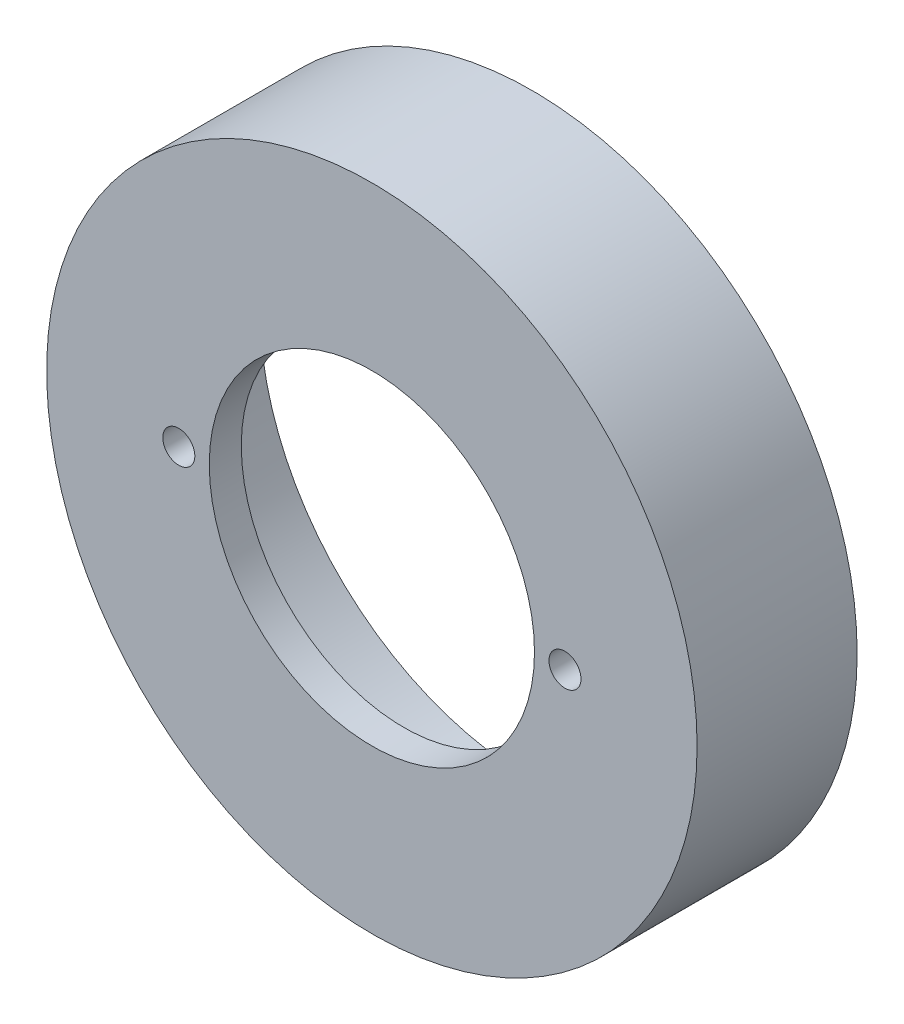
from build123d import *

# Parameters (mm, degrees)
ESQUISSE1_R             = 50.8
BOSS_EXTRU_1_DEPTH      = 25
ESQUISSE2_R             = 25.4
ENL_V_MAT_EXTRU_1_DEPTH = 26
ESQUISSE3_R             = 42.5
ENL_V_MAT_EXTRU_2_DEPTH = 20
ESQUISSE4_R             = 2.5
ENL_V_MAT_EXTRU_3_DEPTH = 6
ESQUISSE5_R             = 2
ENL_V_MAT_EXTRU_4_DEPTH = 7.5


with BuildPart() as part:
    # Esquisse1 → Boss.-Extru.1 (new body)
    with BuildSketch(Plane.XY):
        Circle(ESQUISSE1_R)
    extrude(amount=BOSS_EXTRU_1_DEPTH)

    # Esquisse2 → Enlèv. mat.-Extru.1 (cut, through all)
    with BuildSketch(Plane.XY.offset(25)):
        Circle(ESQUISSE2_R)
    extrude(amount=-ENL_V_MAT_EXTRU_1_DEPTH, mode=Mode.SUBTRACT)

    # Esquisse3 → Enlèv. mat.-Extru.2 (cut)
    with BuildSketch(Plane(origin=(0, 0, 0), x_dir=(-1, 0, 0), z_dir=(0, 0, -1))):
        Circle(ESQUISSE3_R)
    extrude(amount=-ENL_V_MAT_EXTRU_2_DEPTH, mode=Mode.SUBTRACT)

    # Esquisse4 → Enlèv. mat.-Extru.3 (cut, through all)
    with BuildSketch(Plane(origin=(0, 0, 20), x_dir=(-1, 0, 0), z_dir=(0, 0, -1))):
        with Locations((-30.16, 0)):
            Circle(ESQUISSE4_R)
        with Locations((30.16, 0)):
            Circle(ESQUISSE4_R)
    extrude(amount=-ENL_V_MAT_EXTRU_3_DEPTH, mode=Mode.SUBTRACT)

    # Esquisse5 → Enlèv. mat.-Extru.4 (cut)
    with BuildSketch(Plane(origin=(0, 0, 0), x_dir=(-1, 0, 0), z_dir=(0, 0, -1))):
        with Locations((0, 46.647557519)):
            Circle(ESQUISSE5_R)
        with Locations((0, -47.352442481)):
            Circle(ESQUISSE5_R)
    extrude(amount=-ENL_V_MAT_EXTRU_4_DEPTH, mode=Mode.SUBTRACT)


solid = part.part
